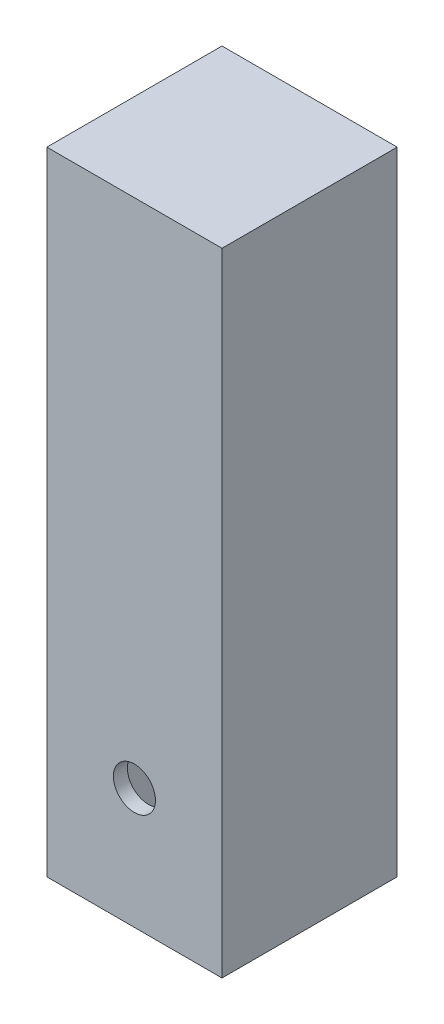
from build123d import *

# Parameters (mm, degrees)
SKETCH1_W                = 25.000000038
SKETCH1_H                = 25.000000038
BOSS_EXTRUDE1_DEPTH      = 120
SHELL1_T                 = -2
F_6_0_6_DIAMETER_HOLE1_D = 6
SKETCH6_W                = 35.234136461
SKETCH6_H                = 40.928418781
CUT_EXTRUDE1_DEPTH       = 48.26
CUT_EXTRUDE2_DEPTH       = 48.26
CUT_EXTRUDE2_DEPTH_BACK  = 48.26
SKETCH6_2_W              = 35.234136461
SKETCH6_2_H              = 40.928418781


with BuildPart() as part:
    # Sketch1 → Boss-Extrude1 (new body)
    with BuildSketch(Plane(origin=(0, 0, 0), x_dir=(1, 0, 0), z_dir=(0, 1, 0))):
        Rectangle(SKETCH1_W, SKETCH1_H)
    extrude(amount=BOSS_EXTRUDE1_DEPTH)

    # Shell1
    shell1_openings = [part.faces().sort_by_distance(p)[0] for p in [
        (0, 0, 0),
    ]]
    offset(amount=SHELL1_T, openings=shell1_openings, kind=Kind.INTERSECTION)

    # Ø6.0 (6) Diameter Hole1 (through all)
    with Locations(Plane.XY.offset(12.500000019)):
        with Locations((0, 46.99999998)):
            Hole(F_6_0_6_DIAMETER_HOLE1_D / 2)

    # Sketch6 → Cut-Extrude1 (cut)
    with BuildSketch(Plane.XY):
        with Locations((1.431161847, 9.333336088)):
            Rectangle(SKETCH6_W, SKETCH6_H)
    extrude(amount=-CUT_EXTRUDE1_DEPTH, mode=Mode.SUBTRACT)

    # Sketch6_2 → Cut-Extrude2 (cut, two sides: drawn at the far end of the back side and taken through both)
    with BuildSketch(Plane.XY.offset(-CUT_EXTRUDE2_DEPTH_BACK)):
        with Locations((1.431161847, 9.333336088)):
            Rectangle(SKETCH6_2_W, SKETCH6_2_H)
    extrude(amount=CUT_EXTRUDE2_DEPTH + CUT_EXTRUDE2_DEPTH_BACK, mode=Mode.SUBTRACT)


solid = part.part
